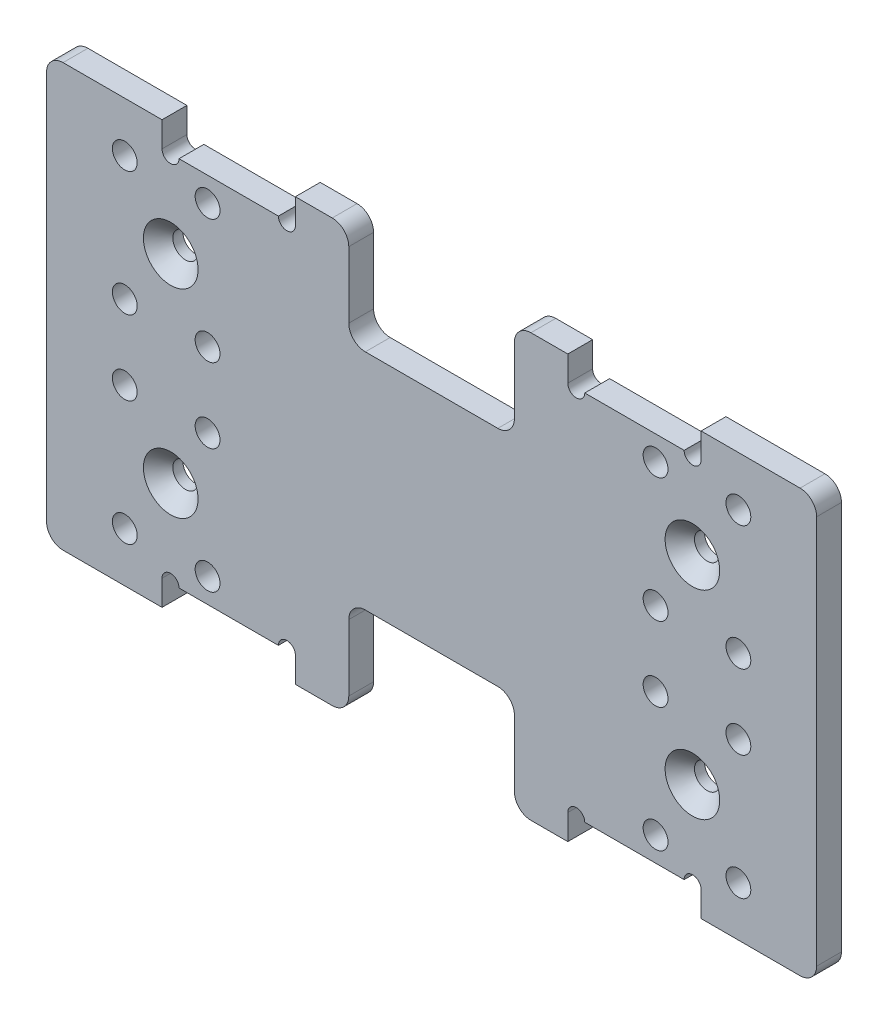
from build123d import *

# Parameters (mm, degrees)
SKETCH_1_W                  = 93
SKETCH_1_H                  = 51
EXTRUDE_1_DEPTH             = 1.5
SKETCH_2_R                  = 1.525
CUT_EXTRUDE_1_DEPTH         = 5
HOLE_WIZARD_M3_1_AT_2_COUNT = 2
HOLE_WIZARD_M3_1_AT_2_PITCH = 63
SKETCH_5_R                  = 1.5
CUT_EXTRUDE_2_DEPTH         = 5
SKETCH_7_W                  = 20
SKETCH_7_H                  = 24
CUT_EXTRUDE_3_DEPTH         = 10
FILLET_1_R                  = 2
SKETCH_8_W                  = 16.1
SKETCH_8_H                  = 3.1
CUT_EXTRUDE_4_DEPTH         = 3
MIRROR_5_COPY_1_SKETCH_W    = 16.1
MIRROR_5_COPY_1_SKETCH_H    = 3.1
MIRROR_5_COPY_1_DEPTH       = 3
SKETCH_9_R                  = 1.025
CUT_EXTRUDE_5_DEPTH         = 3


with BuildPart() as part:
    # 草图1 → 凸台-拉伸1 (new body, symmetric)
    with BuildSketch(Plane.XY):
        Rectangle(SKETCH_1_W, SKETCH_1_H)
    extrude(amount=EXTRUDE_1_DEPTH, both=True)

    # 草图2 → 切除-拉伸1 (cut, symmetric)
    with BuildSketch(Plane.XY.offset(1.5)):
        with Locations((-31.5, 12)):
            Circle(SKETCH_2_R)
        with Locations((31.5, 12)):
            Circle(SKETCH_2_R)
    cut_extrude_1 = extrude(amount=CUT_EXTRUDE_1_DEPTH, both=True, mode=Mode.SUBTRACT)

    # 草图4 → M3 十字槽半沉头木螺钉的锥形沉头孔1 (revolve, cut)
    with BuildSketch(Plane(origin=(-31.5, 12, 1.5), x_dir=(0, -1, 0), z_dir=(1, 0, 0))):
        Polygon((0, 0), (0, 12.401290929), (1.5, 11.5), (1.5, 1.8), (3.3, 0), align=None)
    hole_wizard_m3_1 = revolve(axis=Axis((-31.5, 12, 7.85), (0, 0, -1)), mode=Mode.SUBTRACT)

    # M3 十字槽半沉头木螺钉的锥形沉头孔1 at 2: M3 十字槽半沉头木螺钉的锥形沉头孔1 ×2
    with Locations(*[(i * HOLE_WIZARD_M3_1_AT_2_PITCH, 0, 0) for i in range(1, HOLE_WIZARD_M3_1_AT_2_COUNT)]):
        add(hole_wizard_m3_1, mode=Mode.SUBTRACT)

    # 草图5 → 切除-拉伸2 (cut, symmetric)
    with BuildSketch(Plane(origin=(0, 0, -1.5), x_dir=(-1, 0, 0), z_dir=(0, 0, -1))):
        with Locations((-27.05, 4.5)):
            Circle(SKETCH_5_R)
        with Locations((-37.05, 4.5)):
            Circle(SKETCH_5_R)
        with Locations((-37.05, 19.5)):
            Circle(SKETCH_5_R)
        with Locations((-27.05, 19.5)):
            Circle(SKETCH_5_R)
        with Locations((27.05, 19.5)):
            Circle(SKETCH_5_R)
        with Locations((37.05, 19.5)):
            Circle(SKETCH_5_R)
        with Locations((37.05, 4.5)):
            Circle(SKETCH_5_R)
        with Locations((27.05, 4.5)):
            Circle(SKETCH_5_R)
    cut_extrude_2 = extrude(amount=CUT_EXTRUDE_2_DEPTH, both=True, mode=Mode.SUBTRACT)

    # 镜向1: 切除-拉伸2 across plane
    add(cut_extrude_2.mirror(Plane.ZX), mode=Mode.SUBTRACT)

    # 镜向2: M3 十字槽半沉头木螺钉的锥形沉头孔1, 切除-拉伸1 across plane
    add(hole_wizard_m3_1.mirror(Plane.ZX), mode=Mode.SUBTRACT)
    add(cut_extrude_1.mirror(Plane.ZX), mode=Mode.SUBTRACT)

    # 镜向2 copy 1 sketch → 镜向2 copy 1 (revolve, cut)
    with BuildSketch(Plane(origin=(31.5, -12, 1.5), x_dir=(0, 1, 0), z_dir=(1, 0, 0))):
        Polygon((0, 0), (0, -12.401290929), (1.5, -11.5), (1.5, -1.8), (3.3, 0), align=None)
    revolve(axis=Axis((31.5, -12, 7.85), (0, 0, 1)), mode=Mode.SUBTRACT)

    # 草图7 → 切除-拉伸3 (cut)
    with BuildSketch(Plane(origin=(0, 0, -1.5), x_dir=(-1, 0, 0), z_dir=(0, 0, -1))):
        with Locations((0, -25.5)):
            Rectangle(SKETCH_7_W, SKETCH_7_H)
    cut_extrude_3 = extrude(amount=-CUT_EXTRUDE_3_DEPTH, mode=Mode.SUBTRACT)

    # 镜向3: 切除-拉伸3 across plane
    add(cut_extrude_3.mirror(Plane.ZX), mode=Mode.SUBTRACT)

    # 圆角1
    fillet_1_edges = [part.edges().sort_by_distance(p)[0] for p in [
        (-10, -25.5, 0),
        (-10, -13.5, 0),
        (10, -25.5, 0),
        (10, -13.5, 0),
        (-10, 13.5, 0),
        (10, 13.5, 0),
        (-10, 25.5, 0),
        (10, 25.5, 0),
        (46.5, -25.5, 0),
        (-46.5, -25.5, 0),
        (-46.5, 25.5, 0),
        (46.5, 25.5, 0),
    ]]
    fillet(fillet_1_edges, radius=FILLET_1_R)

    # 草图8 → 切除-拉伸4 (cut)
    with BuildSketch(Plane(origin=(0, 0, -1.5), x_dir=(-1, 0, 0), z_dir=(0, 0, -1))):
        with Locations((-24.5, 24)):
            Rectangle(SKETCH_8_W, SKETCH_8_H)
    cut_extrude_4 = extrude(amount=-CUT_EXTRUDE_4_DEPTH, mode=Mode.SUBTRACT)

    # 镜向4: 切除-拉伸4 across plane
    add(cut_extrude_4.mirror(Plane(origin=(0, 0, 0), x_dir=(0, 0, 1), z_dir=(1, 0, 0))), mode=Mode.SUBTRACT)

    # 镜向5: 切除-拉伸4 across plane
    add(cut_extrude_4.mirror(Plane.ZX), mode=Mode.SUBTRACT)

    # 镜向5 copy 1 sketch → 镜向5 copy 1 (cut)
    with BuildSketch(Plane(origin=(0, 0, -1.5), x_dir=(1, 0, 0), z_dir=(0, 0, -1))):
        with Locations((-24.5, 24)):
            Rectangle(MIRROR_5_COPY_1_SKETCH_W, MIRROR_5_COPY_1_SKETCH_H)
    extrude(amount=-MIRROR_5_COPY_1_DEPTH, mode=Mode.SUBTRACT)

    # 草图9 → 切除-拉伸5 (cut)
    with BuildSketch(Plane.XY.offset(1.5)):
        with Locations((-31.525, 22.45)):
            Circle(SKETCH_9_R)
        with Locations((-17.475, 22.45)):
            Circle(SKETCH_9_R)
        with Locations((17.475, 22.45)):
            Circle(SKETCH_9_R)
        with Locations((31.525, 22.45)):
            Circle(SKETCH_9_R)
    cut_extrude_5 = extrude(amount=-CUT_EXTRUDE_5_DEPTH, mode=Mode.SUBTRACT)

    # 镜向6: 切除-拉伸5 across plane
    add(cut_extrude_5.mirror(Plane.ZX), mode=Mode.SUBTRACT)


solid = part.part
